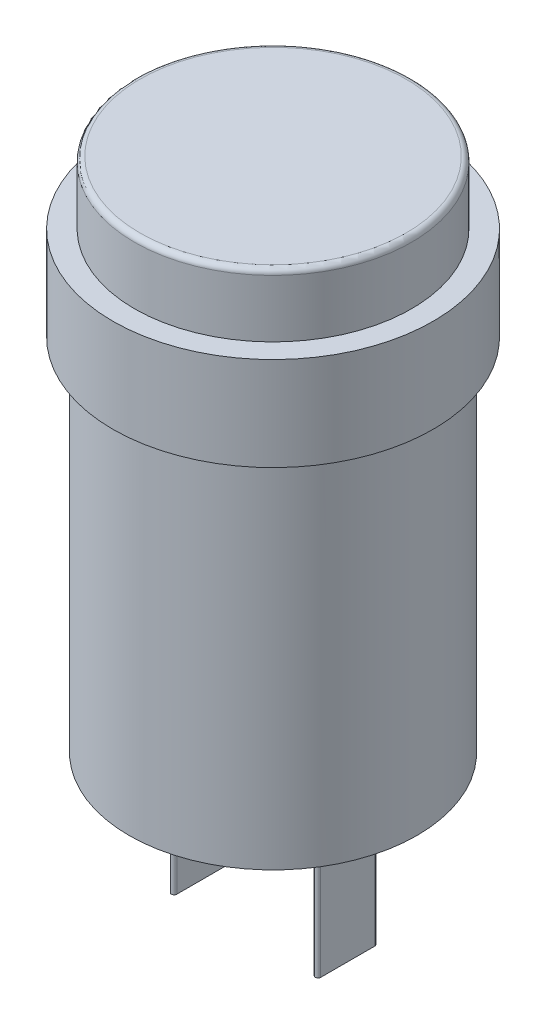
from build123d import *

# Parameters (mm, degrees)
SKETCH1_R           = 8.9
BOSS_EXTRUDE1_DEPTH = 5.2
SKETCH2_R           = 8
BOSS_EXTRUDE2_DEPTH = 20
BOSS_EXTRUDE3_DEPTH = 8
SKETCH4_R           = 7.7
BOSS_EXTRUDE4_DEPTH = 3.5
FILLET1_R           = 0.3
SCALE1_SCALE        = 1.375


with BuildPart() as part:
    # Sketch1 → Boss-Extrude1 (new body)
    with BuildSketch(Plane(origin=(0, 0, 0), x_dir=(1, 0, 0), z_dir=(0, 1, 0))):
        Circle(SKETCH1_R)
    extrude(amount=BOSS_EXTRUDE1_DEPTH)

    # Sketch2 → Boss-Extrude2 (add)
    with BuildSketch(Plane.XZ):
        Circle(SKETCH2_R)
    extrude(amount=BOSS_EXTRUDE2_DEPTH)

    # Sketch3 → Boss-Extrude3 (add)
    with BuildSketch(Plane.XZ.offset(20)):
        with BuildLine():
            Line((4.15, 1.5), (4.15, -1.5))
            ThreePointArc((4.15, -1.5), (4, -1.65), (3.85, -1.5))
            Line((3.85, -1.5), (3.85, 1.5))
            ThreePointArc((3.85, 1.5), (4, 1.65), (4.15, 1.5))
        make_face()
        with BuildLine():
            Line((-3.85, 1.5), (-3.85, -1.5))
            ThreePointArc((-3.85, -1.5), (-4, -1.65), (-4.15, -1.5))
            Line((-4.15, -1.5), (-4.15, 1.5))
            ThreePointArc((-4.15, 1.5), (-4, 1.65), (-3.85, 1.5))
        make_face()
    extrude(amount=BOSS_EXTRUDE3_DEPTH)

    # Sketch4 → Boss-Extrude4 (add)
    with BuildSketch(Plane(origin=(0, 5.2, 0), x_dir=(1, 0, 0), z_dir=(0, 1, 0))):
        Circle(SKETCH4_R)
    extrude(amount=BOSS_EXTRUDE4_DEPTH)

    # Fillet1
    fillet1_edges = [part.edges().sort_by_distance(p)[0] for p in [
        (-7.7, 8.7, 0),
    ]]
    fillet(fillet1_edges, radius=FILLET1_R)


with BuildPart() as part_1:
    # Scale1: scaled about (0, -5.466249854, 0)
    add(part.part.scale(SCALE1_SCALE).moved(Location((0, 2.049843695, 0))))


solid = part_1.part
